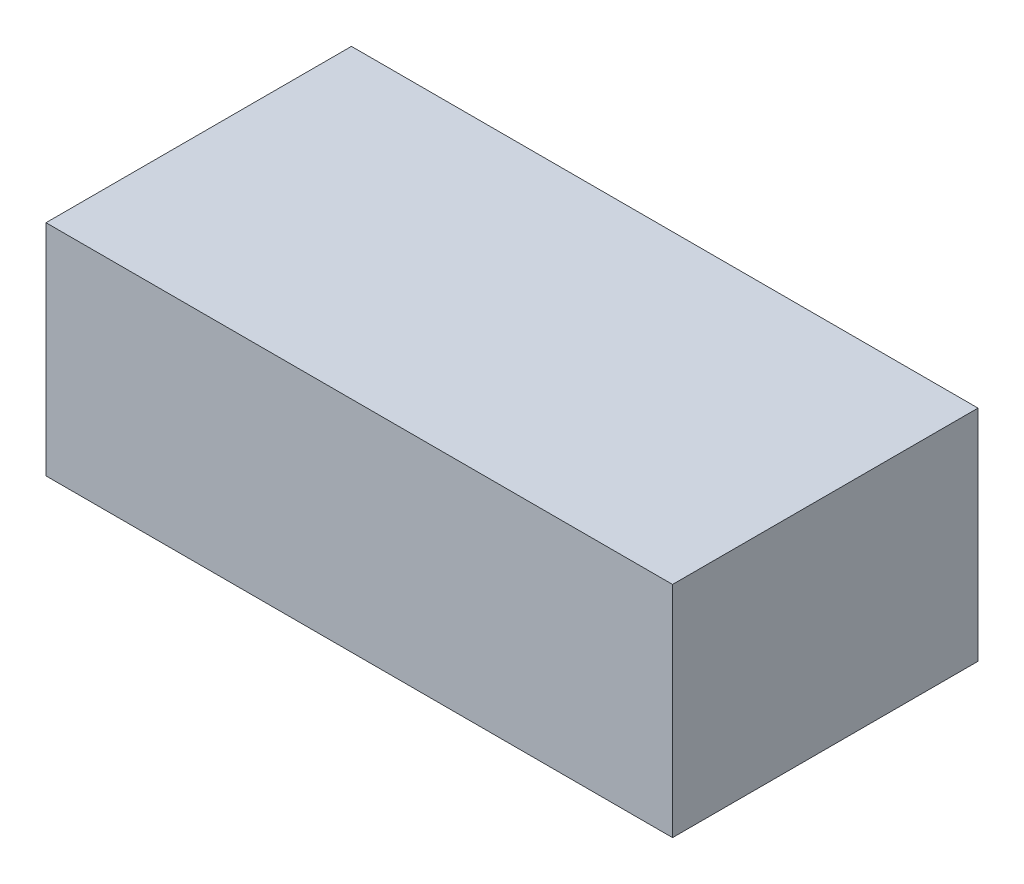
from build123d import *

# Parameters (mm, degrees)
SKETCH1_W           = 80
SKETCH1_H           = 39
BOSS_EXTRUDE1_DEPTH = 28


with BuildPart() as part:
    # Sketch1 → Boss-Extrude1 (new body)
    with BuildSketch(Plane(origin=(0, 0, 0), x_dir=(1, 0, 0), z_dir=(0, 1, 0))):
        with Locations((40, 19.5)):
            Rectangle(SKETCH1_W, SKETCH1_H)
    extrude(amount=BOSS_EXTRUDE1_DEPTH)


solid = part.part
